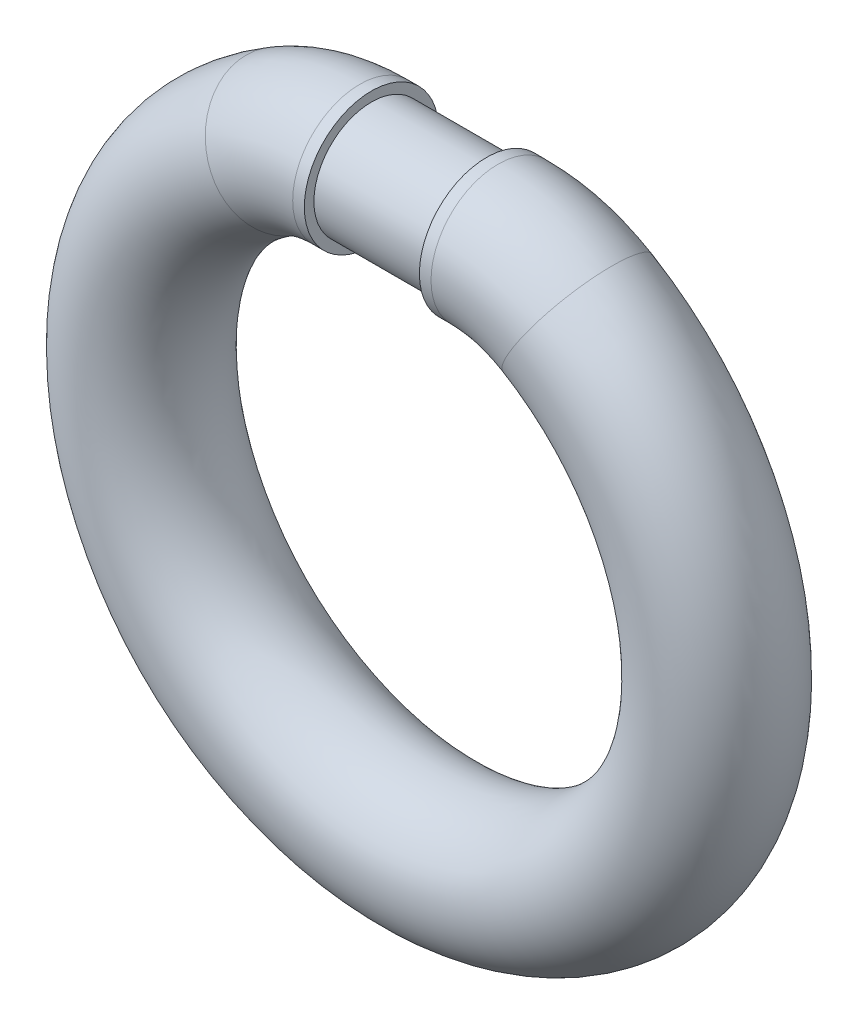
from build123d import *

# Parameters (mm, degrees)
SKETCH_1_W = 60
SKETCH_1_H = 30
SKETCH_3_R = 35


with BuildPart() as part:
    # Эскиз1 → Повернуть1 (revolve)
    with BuildSketch(Plane.XY):
        with Locations((0, 15)):
            Rectangle(SKETCH_1_W, SKETCH_1_H)
    revolve(axis=Axis((-50.256410256, 0, 0), (1, 0, 0)))

    # По траектории1: sweep along a path in Эскиз2
    with BuildLine(Plane.XY) as sweep_1_path:
        Line((-30, 0), (-36.055512755, 0))
        ThreePointArc((-36.055512755, 0), (-57.436412108, -2.910071067), (-77.261813046, -11.428571429))
        ThreePointArc((-77.261813046, -11.428571429), (0, -290), (77.261813046, -11.428571429))
        ThreePointArc((77.261813046, -11.428571429), (57.436412108, -2.910071067), (36.055512755, 0))
        Line((36.055512755, 0), (30, 0))
    # Эскиз3 → По траектории1 (sweep)
    with BuildSketch(Plane.ZY.offset(30)):
        Circle(SKETCH_3_R)
    sweep(path=sweep_1_path.line)


solid = part.part
